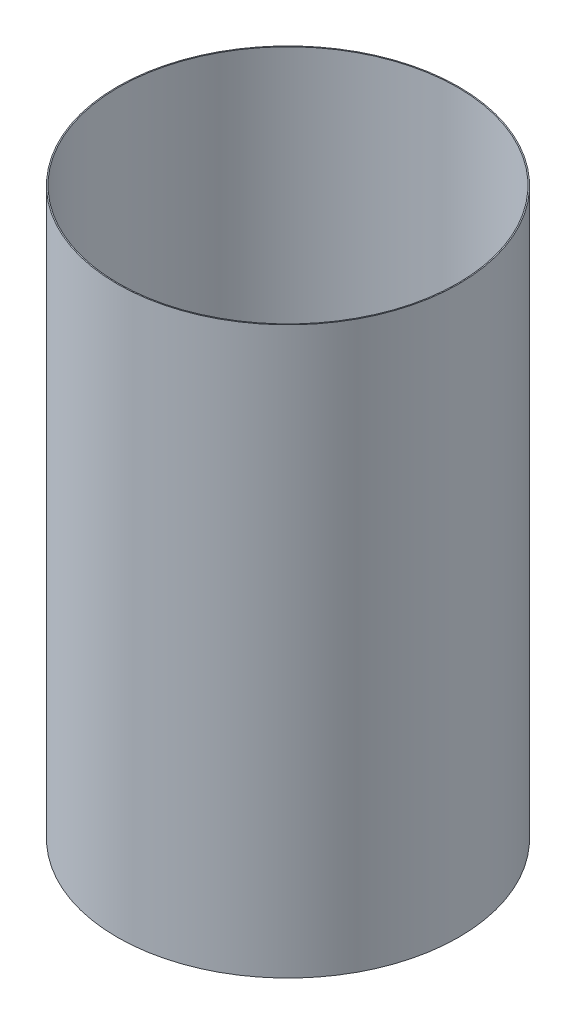
from build123d import *

# Parameters (mm, degrees)
SKETCH1_W = 0.254
SKETCH1_H = 133.35


with BuildPart() as part:
    # Sketch1 → Revolve-Thin1 (revolve)
    with BuildSketch(Plane.XY):
        with Locations((-40.132, -135.67819341)):
            Rectangle(SKETCH1_W, SKETCH1_H)
    revolve(axis=Axis((0, 55, 0), (0, -1, 0)))


solid = part.part
